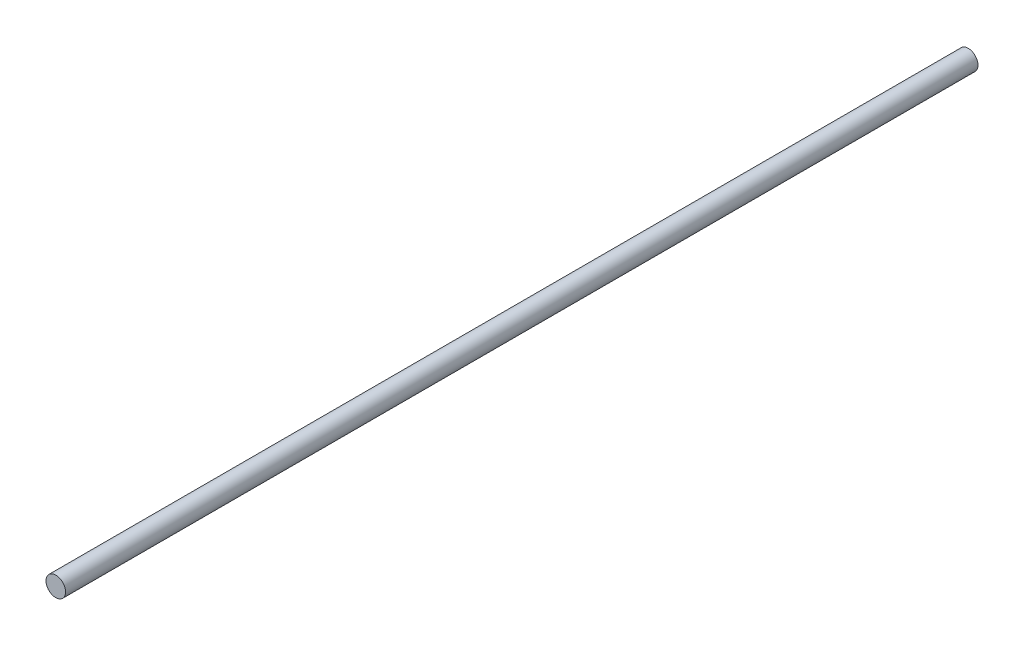
from build123d import *

# Parameters (mm, degrees)
SKETCH_1_R      = 3
EXTRUDE_1_DEPTH = 280


with BuildPart() as part:
    # 草图1 → 凸台-拉伸1 (new body)
    with BuildSketch(Plane.XY):
        Circle(SKETCH_1_R)
    extrude(amount=EXTRUDE_1_DEPTH)


solid = part.part
